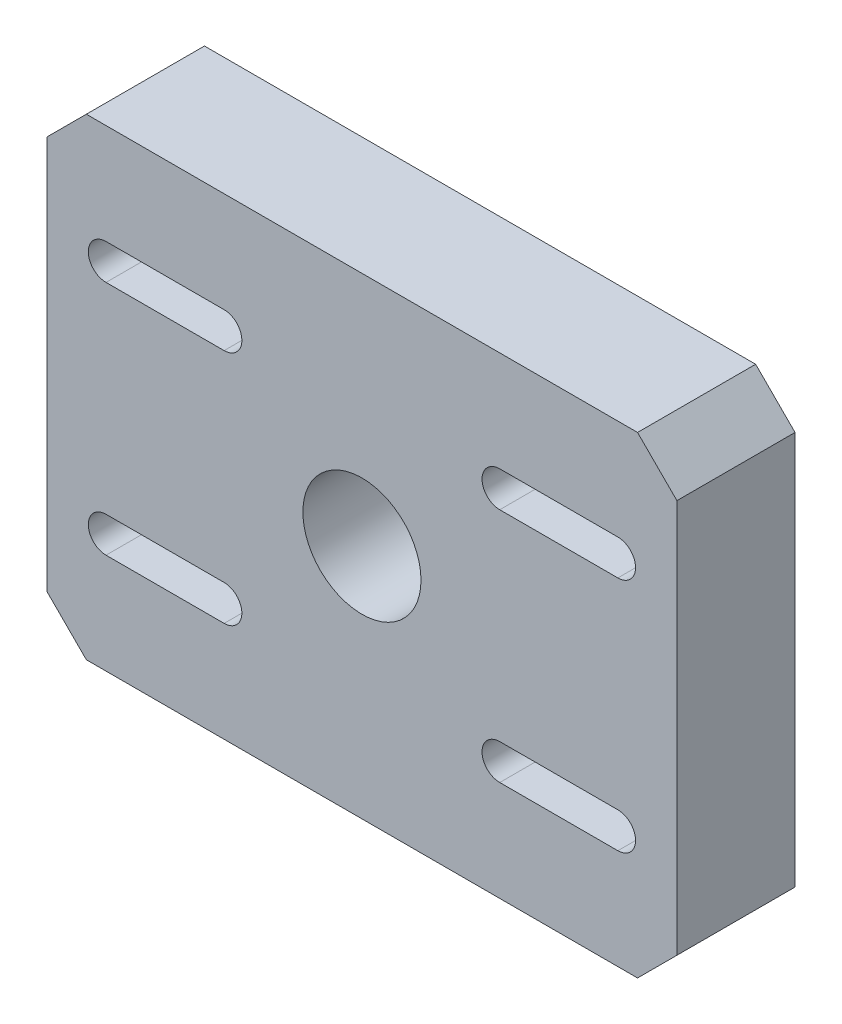
from build123d import *

# Parameters (mm, degrees)
SKETCH_1_W          = 160
SKETCH_1_H          = 120
EXTRUDE_1_DEPTH     = 30
CUT_EXTRUDE_1_DEPTH = 31
CHAMFER_1_SIZE      = 10
SKETCH_3_R          = 15
CUT_EXTRUDE_2_DEPTH = 30


with BuildPart() as part:
    # 草图1 → 凸台-拉伸1 (new body)
    with BuildSketch(Plane.XY):
        Rectangle(SKETCH_1_W, SKETCH_1_H)
    extrude(amount=EXTRUDE_1_DEPTH)

    # 草图2 → 切除-拉伸1 (cut, through all)
    with BuildSketch(Plane.XY.offset(30)):
        with BuildLine():
            Line((-65, 34.5), (-35, 34.5))
            ThreePointArc((-35, 34.5), (-30.5, 30), (-35, 25.5))
            Line((-35, 25.5), (-65, 25.5))
            ThreePointArc((-65, 25.5), (-69.5, 30), (-65, 34.5))
        make_face()
        with BuildLine():
            Line((65, 25.5), (35, 25.5))
            ThreePointArc((35, 25.5), (30.5, 30), (35, 34.5))
            Line((35, 34.5), (65, 34.5))
            ThreePointArc((65, 34.5), (69.5, 30), (65, 25.5))
        make_face()
        with BuildLine():
            Line((-65, -25.5), (-35, -25.5))
            ThreePointArc((-35, -25.5), (-30.5, -30), (-35, -34.5))
            Line((-35, -34.5), (-65, -34.5))
            ThreePointArc((-65, -34.5), (-69.5, -30), (-65, -25.5))
        make_face()
        with BuildLine():
            Line((65, -34.5), (35, -34.5))
            ThreePointArc((35, -34.5), (30.5, -30), (35, -25.5))
            Line((35, -25.5), (65, -25.5))
            ThreePointArc((65, -25.5), (69.5, -30), (65, -34.5))
        make_face()
    extrude(amount=-CUT_EXTRUDE_1_DEPTH, mode=Mode.SUBTRACT)

    # 倒角1
    chamfer_1_edges = [part.edges().sort_by_distance(p)[0] for p in [
        (-80, 60, 15),
        (80, 60, 15),
        (80, -60, 15),
        (-80, -60, 15),
    ]]
    chamfer(chamfer_1_edges, length=CHAMFER_1_SIZE)

    # 草图3 → 切除-拉伸2 (cut)
    with BuildSketch(Plane.XY.offset(30)):
        Circle(SKETCH_3_R)
    extrude(amount=-CUT_EXTRUDE_2_DEPTH, mode=Mode.SUBTRACT)


solid = part.part
